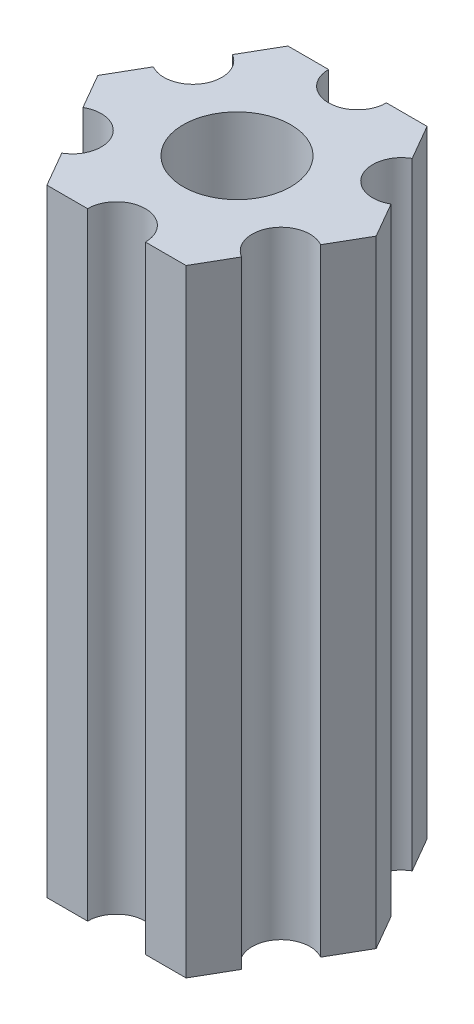
from build123d import *

# Parameters (mm, degrees)
ESBO_O1_R                = 2.79
RESSALTO_EXTRUS_O1_DEPTH = 32


with BuildPart() as part:
    # Esboço1 → Ressalto-extrusão1 (new body)
    with BuildSketch(Plane(origin=(0, 85, 0), x_dir=(1, 0, 0), z_dir=(0, 1, 0))):
        with BuildLine():
            Line((6.162658774, -1.825961894), (7.216878365, 0))
            Line((7.216878365, 0), (6.162658774, 1.825961894))
            ThreePointArc((6.162658774, 1.825961894), (4.113620668, 2.375), (4.662658774, 4.424038106))
            Line((4.662658774, 4.424038106), (3.608439182, 6.25))
            Line((3.608439182, 6.25), (1.5, 6.25))
            ThreePointArc((1.5, 6.25), (0, 4.75), (-1.5, 6.25))
            Line((-1.5, 6.25), (-3.608439182, 6.25))
            Line((-3.608439182, 6.25), (-4.662658774, 4.424038106))
            ThreePointArc((-4.662658774, 4.424038106), (-4.113620668, 2.375), (-6.162658774, 1.825961894))
            Line((-6.162658774, 1.825961894), (-7.216878365, 0))
            Line((-7.216878365, 0), (-6.162658774, -1.825961894))
            ThreePointArc((-6.162658774, -1.825961894), (-4.113620668, -2.375), (-4.662658774, -4.424038106))
            Line((-4.662658774, -4.424038106), (-3.608439182, -6.25))
            Line((-3.608439182, -6.25), (-1.5, -6.25))
            ThreePointArc((-1.5, -6.25), (0, -4.75), (1.5, -6.25))
            Line((1.5, -6.25), (3.608439182, -6.25))
            Line((3.608439182, -6.25), (4.662658774, -4.424038106))
            ThreePointArc((4.662658774, -4.424038106), (4.113620668, -2.375), (6.162658774, -1.825961894))
        make_face()
        Circle(ESBO_O1_R, mode=Mode.SUBTRACT)
    extrude(amount=-RESSALTO_EXTRUS_O1_DEPTH)


solid = part.part
